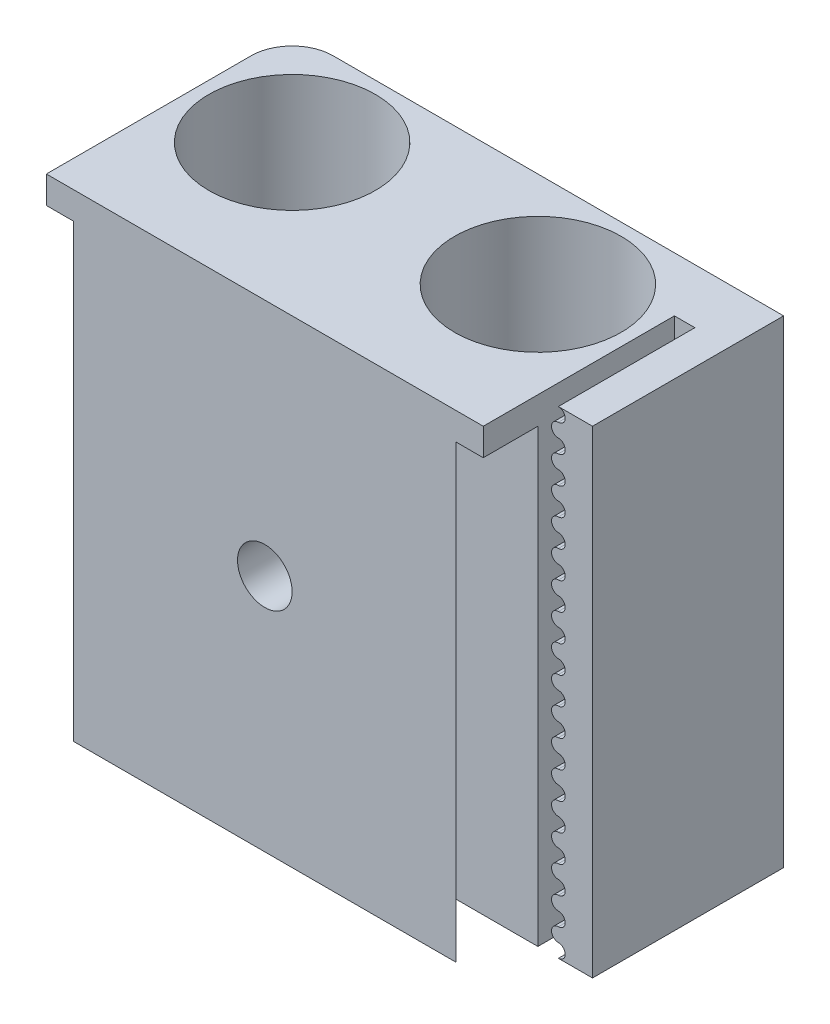
from build123d import *

# Parameters (mm, degrees)
SKETCH_1_W          = 32
SKETCH_1_H          = 35
EXTRUDE_1_DEPTH     = 14
CUT_EXTRUDE_1_REACH = 37
SKETCH_2_R          = 6.1
EXTRUDE_2_DEPTH     = 33
FILLET_1_R          = 3
SKETCH_6_W          = 14
SKETCH_6_H          = 35
EXTRUDE_4_DEPTH     = 4
CUT_EXTRUDE_2_DEPTH = 10
SKETCH_5_W          = 32
SKETCH_5_H          = 4
EXTRUDE_5_DEPTH     = 2
CUT_EXTRUDE_3_REACH = 20
SKETCH_8_R          = 2
CUT_EXTRUDE_4_DEPTH = 3.5


with BuildPart() as part:
    # Эскиз1 → Бобышка-Вытянуть1 (new body)
    with BuildSketch(Plane.XY):
        Rectangle(SKETCH_1_W, SKETCH_1_H)
    extrude(amount=EXTRUDE_1_DEPTH)

    # Эскиз2 → Вырез-Вытянуть1 (cut, up to next)
    with BuildSketch(Plane(origin=(0, 17.5, 0), x_dir=(1, 0, 0), z_dir=(0, 1, 0)), mode=Mode.PRIVATE) as cut_extrude_1_sk1:
        with Locations((-9, -7)):
            Circle(SKETCH_2_R)
    cut_extrude_1_tool1 = extrude(cut_extrude_1_sk1.sketch, amount=-CUT_EXTRUDE_1_REACH, mode=Mode.PRIVATE) & part.part
    add(cut_extrude_1_tool1.solids().sort_by_distance((-9, 17.5, 7))[0], mode=Mode.SUBTRACT)
    # Эскиз2 → Вырез-Вытянуть1 (cut, up to next)
    with BuildSketch(Plane(origin=(0, 17.5, 0), x_dir=(1, 0, 0), z_dir=(0, 1, 0)), mode=Mode.PRIVATE) as cut_extrude_1_sk2:
        with Locations((9, -7)):
            Circle(SKETCH_2_R)
    cut_extrude_1_tool2 = extrude(cut_extrude_1_sk2.sketch, amount=-CUT_EXTRUDE_1_REACH, mode=Mode.PRIVATE) & part.part
    add(cut_extrude_1_tool2.solids().sort_by_distance((9, 17.5, 7))[0], mode=Mode.SUBTRACT)

    # Эскиз3 → Бобышка-Вытянуть2 (add)
    with BuildSketch(Plane(origin=(0, -17.5, 0), x_dir=(1, 0, 0), z_dir=(0, 1, 0))):
        Polygon((-14, -18), (-10, -14), (10, -14), (14, -18), align=None)
    extrude(amount=EXTRUDE_2_DEPTH)

    # Скругление1
    fillet_1_edges = [part.edges().sort_by_distance(p)[0] for p in [
        (-16, 0, 0),
    ]]
    fillet(fillet_1_edges, radius=FILLET_1_R)

    # Эскиз6 → Бобышка-Вытянуть4 (add)
    with BuildSketch(Plane(origin=(16, 0, 0), x_dir=(0, 0, -1), z_dir=(1, 0, 0))):
        with Locations((-7, 0)):
            Rectangle(SKETCH_6_W, SKETCH_6_H)
    extrude(amount=EXTRUDE_4_DEPTH)

    # Эскиз7 → Вырез-Вытянуть2 (cut)
    with BuildSketch(Plane.XY.offset(14)):
        with BuildLine():
            Line((16, -17.5), (17.5, -17.5))
            ThreePointArc((17.5, -17.5), (18, -17), (17.5, -16.5))
            ThreePointArc((17.5, -16.5), (17, -16), (17.5, -15.5))
            ThreePointArc((17.5, -15.5), (18, -15), (17.5, -14.5))
            ThreePointArc((17.5, -14.5), (17, -14), (17.5, -13.5))
            ThreePointArc((17.5, -13.5), (18, -13), (17.5, -12.5))
            ThreePointArc((17.5, -12.5), (17, -12), (17.5, -11.5))
            ThreePointArc((17.5, -11.5), (18, -11), (17.5, -10.5))
            ThreePointArc((17.5, -10.5), (17, -10), (17.5, -9.5))
            ThreePointArc((17.5, -9.5), (18, -9), (17.5, -8.5))
            ThreePointArc((17.5, -8.5), (17, -8), (17.5, -7.5))
            ThreePointArc((17.5, -7.5), (18, -7), (17.5, -6.5))
            ThreePointArc((17.5, -6.5), (17, -6), (17.5, -5.5))
            ThreePointArc((17.5, -5.5), (18, -5), (17.5, -4.5))
            ThreePointArc((17.5, -4.5), (17, -4), (17.5, -3.5))
            ThreePointArc((17.5, -3.5), (18, -3), (17.5, -2.5))
            ThreePointArc((17.5, -2.5), (17, -2), (17.5, -1.5))
            ThreePointArc((17.5, -1.5), (18, -1), (17.5, -0.5))
            ThreePointArc((17.5, -0.5), (17, 0), (17.5, 0.5))
            ThreePointArc((17.5, 0.5), (18, 1), (17.5, 1.5))
            ThreePointArc((17.5, 1.5), (17, 2), (17.5, 2.5))
            ThreePointArc((17.5, 2.5), (18, 3), (17.5, 3.5))
            ThreePointArc((17.5, 3.5), (17, 4), (17.5, 4.5))
            ThreePointArc((17.5, 4.5), (18, 5), (17.5, 5.5))
            ThreePointArc((17.5, 5.5), (17, 6), (17.5, 6.5))
            ThreePointArc((17.5, 6.5), (18, 7), (17.5, 7.5))
            ThreePointArc((17.5, 7.5), (17, 8), (17.5, 8.5))
            ThreePointArc((17.5, 8.5), (18, 9), (17.5, 9.5))
            ThreePointArc((17.5, 9.5), (17, 10), (17.5, 10.5))
            ThreePointArc((17.5, 10.5), (18, 11), (17.5, 11.5))
            ThreePointArc((17.5, 11.5), (17, 12), (17.5, 12.5))
            ThreePointArc((17.5, 12.5), (18, 13), (17.5, 13.5))
            ThreePointArc((17.5, 13.5), (17, 14), (17.5, 14.5))
            ThreePointArc((17.5, 14.5), (18, 15), (17.5, 15.5))
            ThreePointArc((17.5, 15.5), (17, 16), (17.5, 16.5))
            ThreePointArc((17.5, 16.5), (18, 17), (17.5, 17.5))
            Line((17.5, 17.5), (16, 17.5))
            Line((16, 17.5), (16, -17.5))
        make_face()
    extrude(amount=-CUT_EXTRUDE_2_DEPTH, mode=Mode.SUBTRACT)

    # Эскиз5 → Бобышка-Вытянуть5 (add)
    with BuildSketch(Plane(origin=(0, 15.5, 0), x_dir=(-1, 0, 0), z_dir=(0, 1, 0))):
        with Locations((0, 16)):
            Rectangle(SKETCH_5_W, SKETCH_5_H)
    extrude(amount=EXTRUDE_5_DEPTH)

    # Эскиз8 → Вырез-Вытянуть3 (cut, up to next)
    with BuildSketch(Plane.XY.offset(18), mode=Mode.PRIVATE) as cut_extrude_3_sk1:
        Circle(SKETCH_8_R)
    cut_extrude_3_tool1 = extrude(cut_extrude_3_sk1.sketch, amount=-CUT_EXTRUDE_3_REACH, mode=Mode.PRIVATE) & part.part
    add(cut_extrude_3_tool1.solids().sort_by_distance((0, 0, 18))[0], mode=Mode.SUBTRACT)

    # Эскиз9 → Вырез-Вытянуть4 (cut)
    with BuildSketch(Plane(origin=(0, 0, 0), x_dir=(-1, 0, 0), z_dir=(0, 0, -1))):
        Polygon((0, -4.041451884), (3.5, -2.020725942), (3.5, 2.020725942), (0, 4.041451884), (-3.5, 2.020725942), (-3.5, -2.020725942), align=None)
    extrude(amount=-CUT_EXTRUDE_4_DEPTH, mode=Mode.SUBTRACT)


solid = part.part
